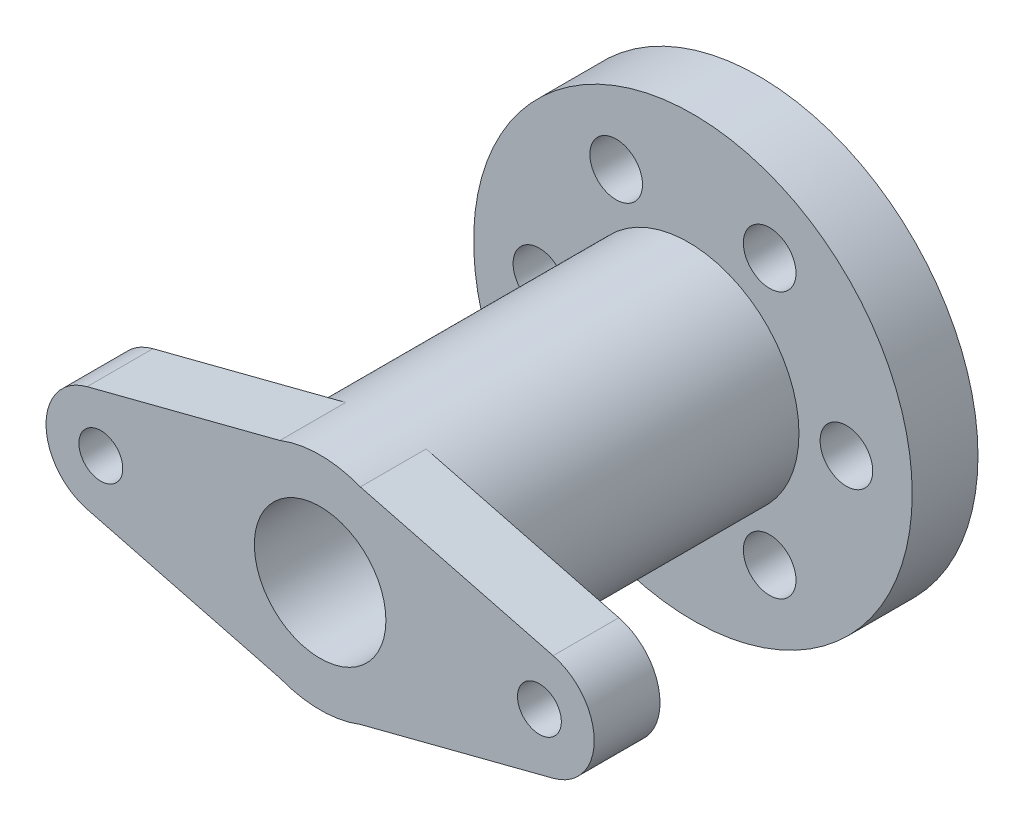
from build123d import *

# Parameters (mm, degrees)
SKETCH1_R           = 50
SKETCH1_R_2         = 6
SKETCH1_R_3         = 15
BOSS_EXTRUDE1_DEPTH = 15
SKETCH1_3_R         = 15
BOSS_EXTRUDE2_DEPTH = 85
SKETCH2_R           = 15
SKETCH2_R_2         = 5
BOSS_EXTRUDE3_DEPTH = 15
SKETCH3_R           = 25.181893643
BOSS_EXTRUDE4_DEPTH = 84
CUT_EXTRUDE1_START  = -120
SKETCH4_R           = 15
CUT_EXTRUDE1_DEPTH  = 120


with BuildPart() as part:
    # Sketch1 → Boss-Extrude1 (new body)
    with BuildSketch(Plane.XY):
        Circle(SKETCH1_R)
        with Locations((17.5, 30.310889132)):
            Circle(SKETCH1_R_2, mode=Mode.SUBTRACT)
        with Locations((-17.5, 30.310889132)):
            Circle(SKETCH1_R_2, mode=Mode.SUBTRACT)
        with Locations((-35, 0)):
            Circle(SKETCH1_R_2, mode=Mode.SUBTRACT)
        with Locations((-17.5, -30.310889132)):
            Circle(SKETCH1_R_2, mode=Mode.SUBTRACT)
        with Locations((17.5, -30.310889132)):
            Circle(SKETCH1_R_2, mode=Mode.SUBTRACT)
        with Locations((35, 0)):
            Circle(SKETCH1_R_2, mode=Mode.SUBTRACT)
        Circle(SKETCH1_R_3, mode=Mode.SUBTRACT)
    extrude(amount=BOSS_EXTRUDE1_DEPTH)

    # Sketch1_3 → Boss-Extrude2 (add)
    with BuildSketch(Plane.XY):
        Circle(SKETCH1_3_R)
    extrude(amount=BOSS_EXTRUDE2_DEPTH)



with BuildPart() as body_2:
    # Sketch2 → Boss-Extrude3 (new body)
    with BuildSketch(Plane.XY.offset(85)):
        with BuildLine():
            Line((-53.125, 12.103072957), (-6.25, 24.206145914))
            ThreePointArc((-6.25, 24.206145914), (0, 25), (6.25, 24.206145914))
            Line((6.25, 24.206145914), (53.125, 12.103072957))
            ThreePointArc((53.125, 12.103072957), (62.5, 0), (53.125, -12.103072957))
            Line((53.125, -12.103072957), (6.25, -24.206145914))
            ThreePointArc((6.25, -24.206145914), (0, -25), (-6.25, -24.206145914))
            Line((-6.25, -24.206145914), (-53.125, -12.103072957))
            ThreePointArc((-53.125, -12.103072957), (-62.5, 0), (-53.125, 12.103072957))
        make_face()
        Circle(SKETCH2_R, mode=Mode.SUBTRACT)
        with Locations((-50, 0)):
            Circle(SKETCH2_R_2, mode=Mode.SUBTRACT)
        with Locations((50, 0)):
            Circle(SKETCH2_R_2, mode=Mode.SUBTRACT)
    extrude(amount=BOSS_EXTRUDE3_DEPTH)


with BuildPart() as part_1:
    add(part.part)

    add(body_2.part)  # Boss-Extrude4 merges body 2
    # Sketch3 → Boss-Extrude4 (add)
    with BuildSketch(Plane.XY.offset(100)):
        Circle(SKETCH3_R)
    extrude(amount=-BOSS_EXTRUDE4_DEPTH)

    # Sketch4 → Cut-Extrude1 (cut)
    with BuildSketch(Plane.XY.offset(100).offset(CUT_EXTRUDE1_START)):
        Circle(SKETCH4_R)
    extrude(amount=CUT_EXTRUDE1_DEPTH, mode=Mode.SUBTRACT)


with BuildPart() as cut_extrude1_piece_1:
    # of the separate pieces the step leaves, piece 1, a body of its own (cut_extrude1_pieces)
    add(part_1.part.solids().sort_by_distance((25.181893643, 0, 16))[0])


with BuildPart() as cut_extrude1_piece_2:
    # of the separate pieces the step leaves, piece 2, a body of its own (cut_extrude1_pieces)
    add(part_1.part.solids().sort_by_distance((50, 0, 0))[0])


solid = Compound([cut_extrude1_piece_1.part, cut_extrude1_piece_2.part])
